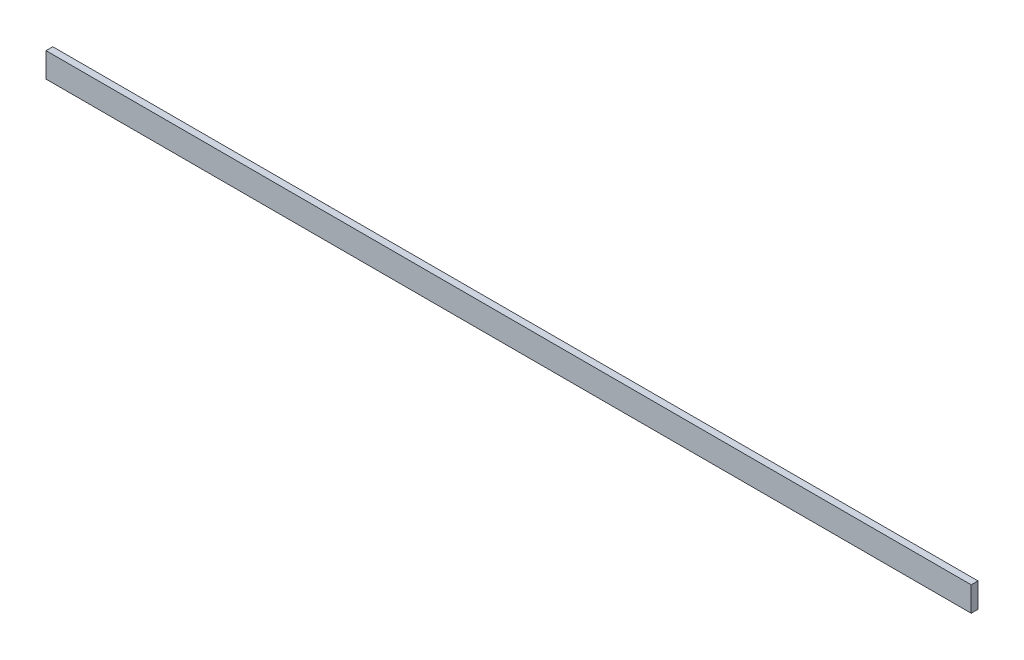
from build123d import *

# Parameters (mm, degrees)
ESQUISSE1_W      = 3000
ESQUISSE1_H      = 22
EXTRUSION1_DEPTH = 80


with BuildPart() as part:
    # Esquisse1 → Extrusion1 (new body)
    with BuildSketch(Plane(origin=(0, 0, 0), x_dir=(1, 0, 0), z_dir=(0, 1, 0))):
        with Locations((1500, 11)):
            Rectangle(ESQUISSE1_W, ESQUISSE1_H)
    extrude(amount=EXTRUSION1_DEPTH)


solid = part.part
